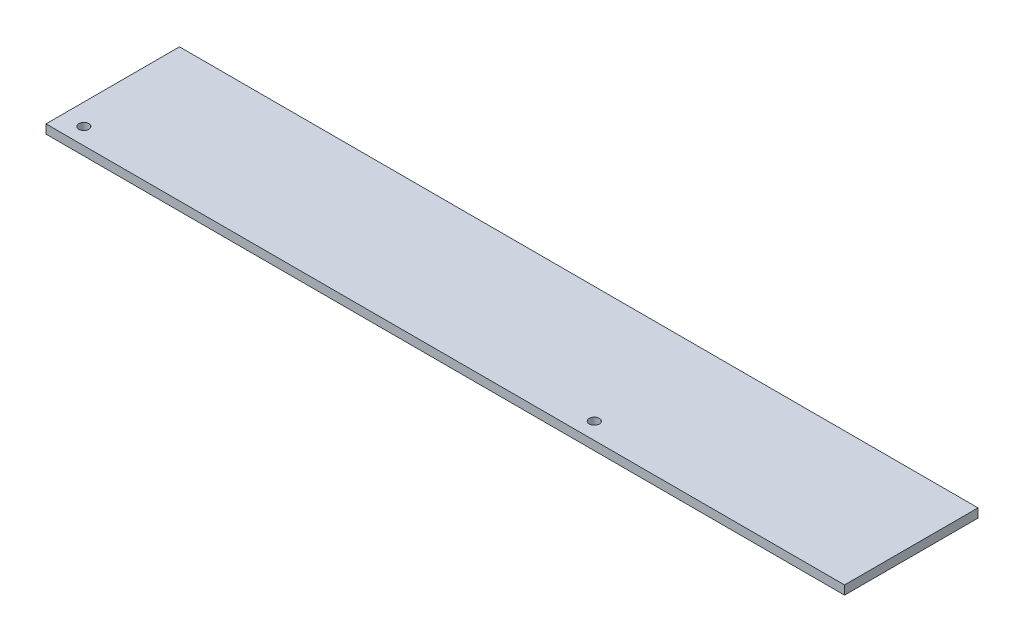
from build123d import *

# Parameters (mm, degrees)
SKETCH_1_W          = 60
SKETCH_1_H          = 4
EXTRUDE_1_DEPTH     = 359
SKETCH_2_R          = 2.25
CUT_EXTRUDE_1_DEPTH = 5


with BuildPart() as part:
    # Эскиз1 → Бобышка-Вытянуть1 (new body)
    with BuildSketch(Plane(origin=(0, 0, 0), x_dir=(0, 0, -1), z_dir=(1, 0, 0))):
        Rectangle(SKETCH_1_W, SKETCH_1_H)
    extrude(amount=EXTRUDE_1_DEPTH)

    # Эскиз2 → Вырез-Вытянуть1 (cut, through all)
    with BuildSketch(Plane(origin=(0, 2, 0), x_dir=(1, 0, 0), z_dir=(0, 1, 0))):
        with Locations((9.5, -22.5)):
            Circle(SKETCH_2_R)
        with Locations((239, -22.5)):
            Circle(SKETCH_2_R)
    extrude(amount=-CUT_EXTRUDE_1_DEPTH, mode=Mode.SUBTRACT)


solid = part.part
